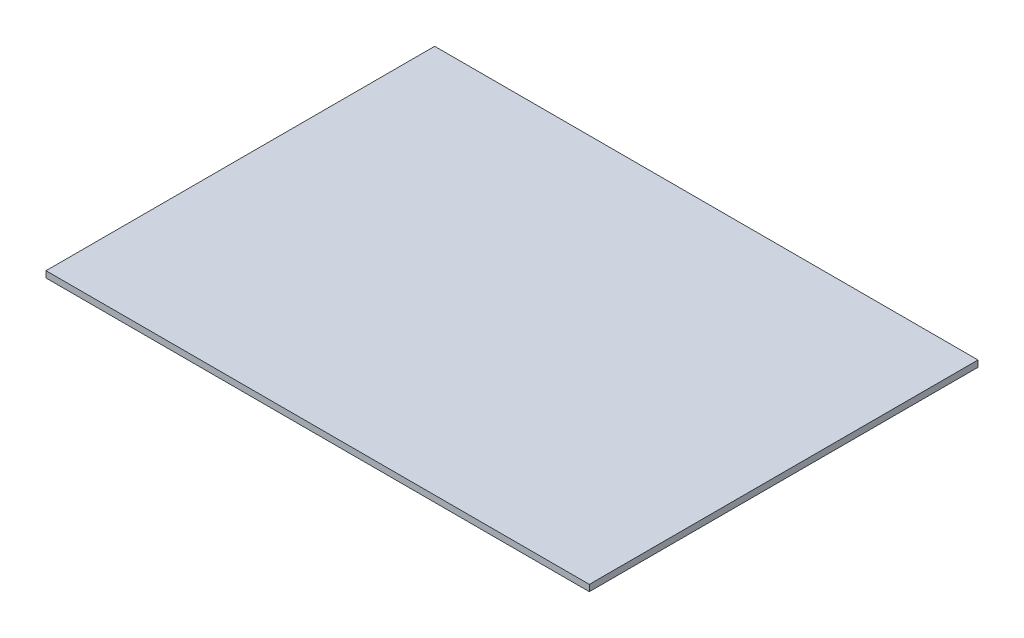
from build123d import *

# Parameters (mm, degrees)
SKETCH1_W           = 260
SKETCH1_H           = 186
BOSS_EXTRUDE1_DEPTH = 3.048


with BuildPart() as part:
    # Sketch1 → Boss-Extrude1 (new body)
    with BuildSketch(Plane(origin=(0, 0, 0), x_dir=(1, 0, 0), z_dir=(0, 1, 0))):
        with Locations((130, 93)):
            Rectangle(SKETCH1_W, SKETCH1_H)
    extrude(amount=BOSS_EXTRUDE1_DEPTH)


solid = part.part
